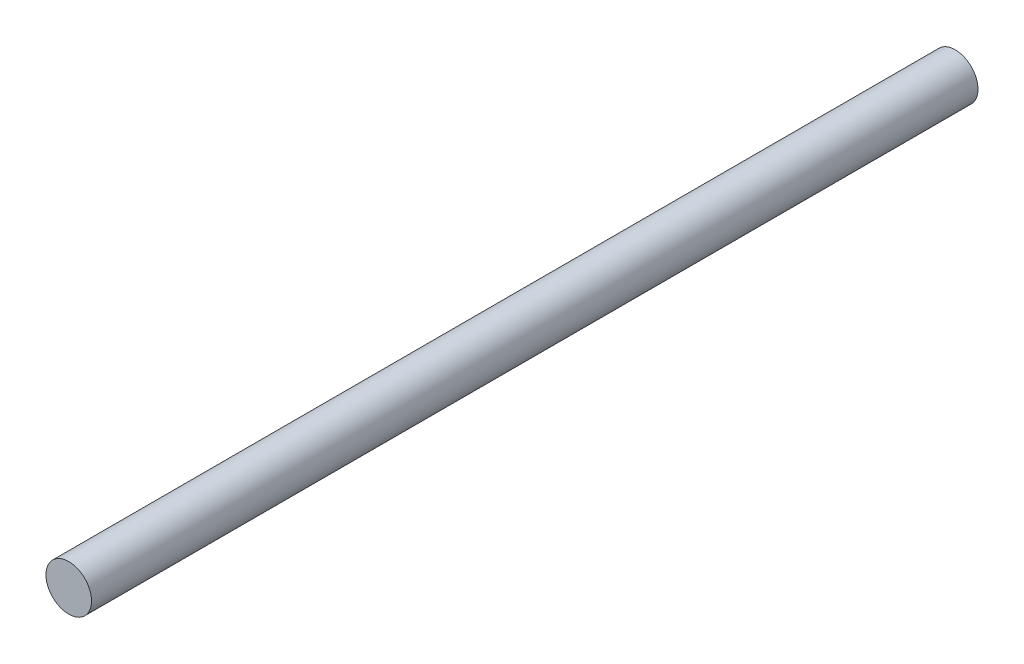
from build123d import *

# Parameters (mm, degrees)
SKETCH1_R           = 14.5034
BOSS_EXTRUDE1_DEPTH = 563.88


with BuildPart() as part:
    # Sketch1 → Boss-Extrude1 (new body)
    with BuildSketch(Plane.XY):
        Circle(SKETCH1_R)
    extrude(amount=BOSS_EXTRUDE1_DEPTH)


solid = part.part
